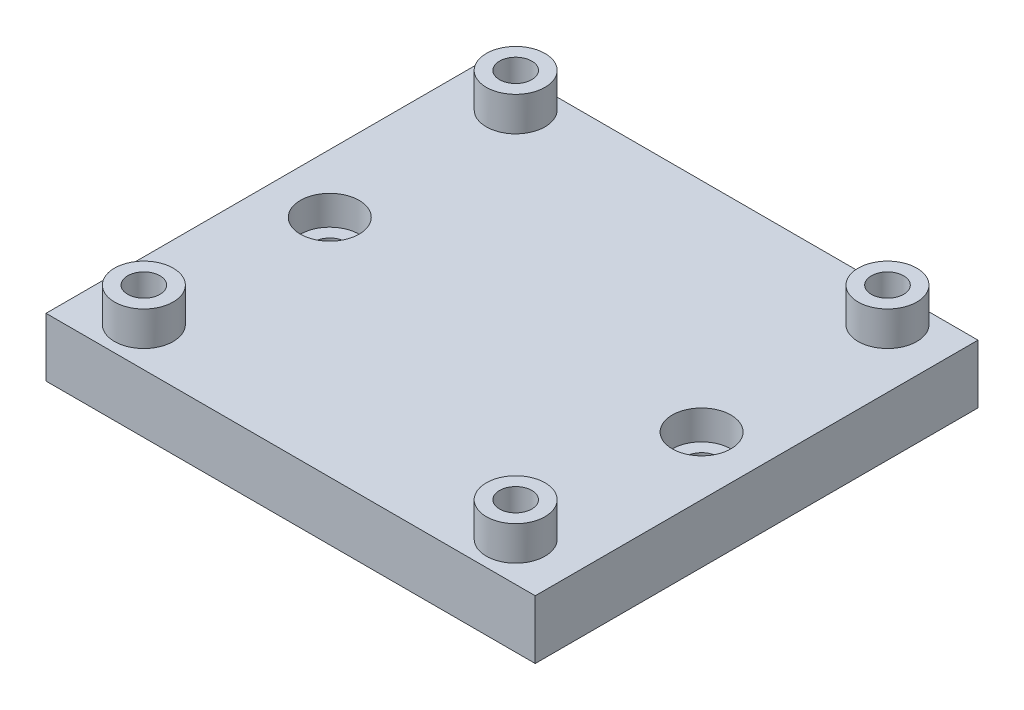
from build123d import *

# Parameters (mm, degrees)
SKETCH2_W           = 50
SKETCH2_H           = 55
SKETCH2_R           = 1.65
BOSS_EXTRUDE2_DEPTH = 6
CUT_EXTRUDE1_START  = 1.8
CUT_EXTRUDE1_DEPTH  = 2.4
SKETCH4_R           = 3
SKETCH4_R_2         = 1.65
BOSS_EXTRUDE3_DEPTH = 3.5
SKETCH5_R           = 3
CUT_EXTRUDE2_DEPTH  = 3
SKETCH6_W           = 50
SKETCH6_H           = 3.75
SKETCH6_H_2         = 6
CUT_EXTRUDE3_DEPTH  = 10


with BuildPart() as part:
    # Sketch2 → Boss-Extrude2 (new body)
    with BuildSketch(Plane(origin=(0, 0, 0), x_dir=(1, 0, 0), z_dir=(0, 1, 0))):
        with Locations((25, 27.5)):
            Rectangle(SKETCH2_W, SKETCH2_H)
        with Locations((6, 10)):
            Circle(SKETCH2_R, mode=Mode.SUBTRACT)
        with Locations((44, 10)):
            Circle(SKETCH2_R, mode=Mode.SUBTRACT)
        with Locations((44, 48)):
            Circle(SKETCH2_R, mode=Mode.SUBTRACT)
        with Locations((6, 48)):
            Circle(SKETCH2_R, mode=Mode.SUBTRACT)
        with Locations((6, 29)):
            Circle(SKETCH2_R, mode=Mode.SUBTRACT)
        with Locations((44, 29)):
            Circle(SKETCH2_R, mode=Mode.SUBTRACT)
    extrude(amount=BOSS_EXTRUDE2_DEPTH)

    # Sketch3 → Cut-Extrude1 (cut)
    with BuildSketch(Plane(origin=(0, 0, 0), x_dir=(1, 0, 0), z_dir=(0, 1, 0)).offset(CUT_EXTRUDE1_START)):
        Polygon((9.233161507, 48), (7.616580754, 50.8), (4.383419246, 50.8), (2.766838493, 48), (4.383419246, 45.2), (7.616580754, 45.2), align=None)
        Polygon((47.233161507, 48), (45.616580754, 50.8), (42.383419246, 50.8), (40.766838493, 48), (42.383419246, 45.2), (45.616580754, 45.2), align=None)
        Polygon((47.233161507, 10), (45.616580754, 12.8), (42.383419246, 12.8), (40.766838493, 10), (42.383419246, 7.2), (45.616580754, 7.2), align=None)
        Polygon((9.233161507, 10), (7.616580754, 12.8), (4.383419246, 12.8), (2.766838493, 10), (4.383419246, 7.2), (7.616580754, 7.2), align=None)
    extrude(amount=CUT_EXTRUDE1_DEPTH, mode=Mode.SUBTRACT)

    # Sketch4 → Boss-Extrude3 (add)
    with BuildSketch(Plane(origin=(0, 6, 0), x_dir=(1, 0, 0), z_dir=(0, 1, 0))):
        with Locations((6, 10)):
            Circle(SKETCH4_R)
        with Locations((6, 10)):
            Circle(SKETCH4_R_2, mode=Mode.SUBTRACT)
        with Locations((44, 10)):
            Circle(SKETCH4_R)
        with Locations((44, 10)):
            Circle(SKETCH4_R_2, mode=Mode.SUBTRACT)
        with Locations((6, 48)):
            Circle(SKETCH4_R)
        with Locations((6, 48)):
            Circle(SKETCH4_R_2, mode=Mode.SUBTRACT)
        with Locations((44, 48)):
            Circle(SKETCH4_R)
        with Locations((44, 48)):
            Circle(SKETCH4_R_2, mode=Mode.SUBTRACT)
    extrude(amount=BOSS_EXTRUDE3_DEPTH)

    # Sketch5 → Cut-Extrude2 (cut)
    with BuildSketch(Plane(origin=(0, 6, 0), x_dir=(1, 0, 0), z_dir=(0, 1, 0))):
        with Locations((6, 29)):
            Circle(SKETCH5_R)
        with Locations((44, 29)):
            Circle(SKETCH5_R)
    extrude(amount=-CUT_EXTRUDE2_DEPTH, mode=Mode.SUBTRACT)

    # Sketch6 → Cut-Extrude3 (cut)
    with BuildSketch(Plane(origin=(0, 6, 0), x_dir=(1, 0, 0), z_dir=(0, 1, 0))):
        with Locations((25, 53.125)):
            Rectangle(SKETCH6_W, SKETCH6_H)
        with Locations((25, 3)):
            Rectangle(SKETCH6_W, SKETCH6_H_2)
    extrude(amount=-CUT_EXTRUDE3_DEPTH, mode=Mode.SUBTRACT)


solid = part.part
